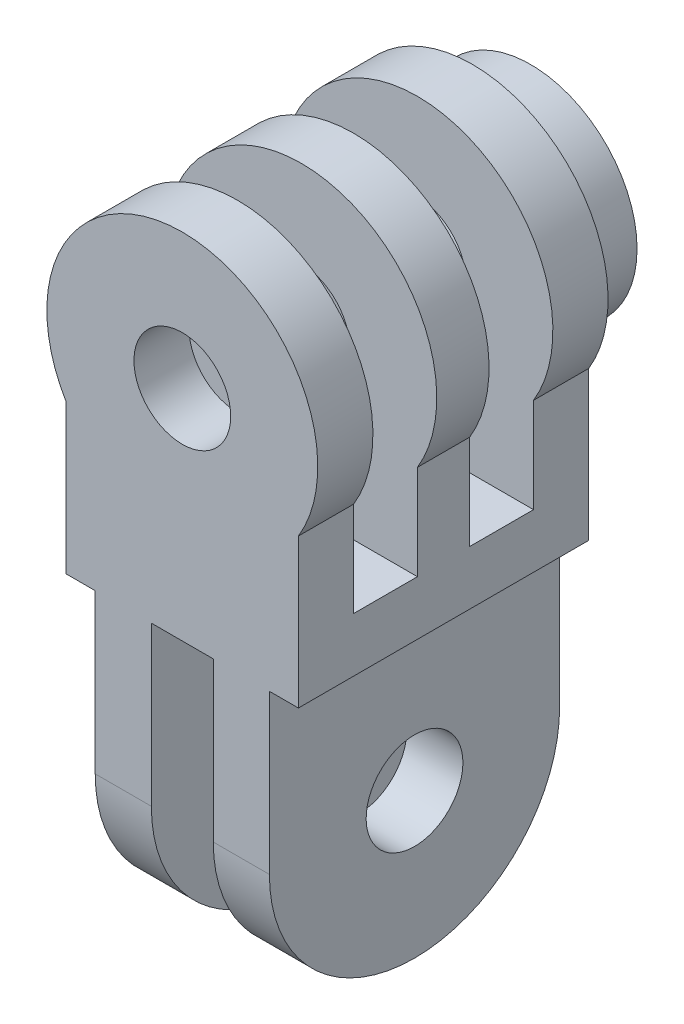
from build123d import *

# Parameters (mm, degrees)
ESQUISSE1_R                  = 2.5
BOSS_EXTRU_1_DEPTH           = 15
ESQUISSE2_W                  = 3.3
ESQUISSE2_H                  = 15.5
ENL_V_MAT_EXTRU_1_DEPTH      = 3.5
ENL_V_MAT_EXTRU_1_DEPTH_BACK = 12.5
ESQUISSE5_R                  = 2.5
ENL_V_MAT_EXTRU_4_DEPTH      = 10
ESQUISSE6_R                  = 5.5
ESQUISSE6_R_2                = 2.5
BOSS_EXTRU_2_DEPTH           = 3
ENL_V_MAT_EXTRU_5_DEPTH      = 3


with BuildPart() as part:
    # Esquisse1 → Boss.-Extru.1 (new body)
    with BuildSketch(Plane.XY):
        with BuildLine():
            Line((-4.5, -1.302598386), (-4.5, -17))
            Line((-4.5, -17), (-1.6, -17))
            Line((-1.6, -17), (-1.6, -1.302598386))
            Line((-1.6, -1.302598386), (1.6, -1.302598386))
            Line((1.6, -1.302598386), (1.6, -17))
            Line((1.6, -17), (4.5, -17))
            Line((4.5, -17), (4.5, -1.302598386))
            Line((4.5, -1.302598386), (6, -1.302598386))
            Line((6, -1.302598386), (6, 6.394448725))
            ThreePointArc((6, 6.394448725), (0, 3), (-6, 6.394448725))
            Line((-6, 6.394448725), (-6, -1.302598386))
            Line((-6, -1.302598386), (-4.5, -1.302598386))
        make_face()
        with BuildLine():
            Line((-6, 13.605551275), (-6, 6.394448725))
            ThreePointArc((-6, 6.394448725), (0, 3), (6, 6.394448725))
            Line((6, 6.394448725), (6, 13.605551275))
            ThreePointArc((6, 13.605551275), (3.446820352, 16.092571663), (0, 17))
            ThreePointArc((0, 17), (-3.446820352, 16.092571663), (-6, 13.605551275))
        make_face()
        with Locations((0, 10)):
            Circle(ESQUISSE1_R, mode=Mode.SUBTRACT)
        with BuildLine():
            Line((6, 13.605551275), (6, 6.394448725))
            ThreePointArc((6, 6.394448725), (6.745368782, 8.129171307), (7, 10))
            ThreePointArc((7, 10), (6.745368782, 11.870828693), (6, 13.605551275))
        make_face()
        with BuildLine():
            ThreePointArc((-6, 13.605551275), (-7, 10), (-6, 6.394448725))
            Line((-6, 6.394448725), (-6, 13.605551275))
        make_face()
    extrude(amount=BOSS_EXTRU_1_DEPTH)

    # Esquisse2 → Enlèv. mat.-Extru.1 (cut, two sides)
    with BuildSketch(Plane(origin=(4.5, 0, 0), x_dir=(0, 0, -1), z_dir=(1, 0, 0))) as enl_v_mat_extru_1_sk:
        with Locations((-10.5, 9.25)):
            Rectangle(ESQUISSE2_W, ESQUISSE2_H)
        with Locations((-4.5, 9.25)):
            Rectangle(ESQUISSE2_W, ESQUISSE2_H)
    extrude(amount=ENL_V_MAT_EXTRU_1_DEPTH, mode=Mode.SUBTRACT)
    extrude(enl_v_mat_extru_1_sk.sketch, amount=-ENL_V_MAT_EXTRU_1_DEPTH_BACK, mode=Mode.SUBTRACT)

    # Esquisse5 → Enlèv. mat.-Extru.4 (cut)
    with BuildSketch(Plane(origin=(4.5, 0, 0), x_dir=(0, 0, -1), z_dir=(1, 0, 0))):
        with BuildLine():
            ThreePointArc((-7.5, -17), (-12.803300859, -14.803300859), (-15, -9.5))
            Line((-15, -9.5), (-15, -17))
            Line((-15, -17), (-7.5, -17))
        make_face()
        with BuildLine():
            Line((0, -17), (0, -9.5))
            ThreePointArc((0, -9.5), (-2.196699141, -14.803300859), (-7.5, -17))
            Line((-7.5, -17), (0, -17))
        make_face()
        with Locations((-7.5, -9.5)):
            Circle(ESQUISSE5_R)
    extrude(amount=-ENL_V_MAT_EXTRU_4_DEPTH, mode=Mode.SUBTRACT)

    # Esquisse6 → Boss.-Extru.2 (add)
    with BuildSketch(Plane(origin=(0, 0, 0), x_dir=(-1, 0, 0), z_dir=(0, 0, -1))):
        with Locations((0, 10)):
            Circle(ESQUISSE6_R)
        with Locations((0, 10)):
            Circle(ESQUISSE6_R_2, mode=Mode.SUBTRACT)
    extrude(amount=BOSS_EXTRU_2_DEPTH)

    # Esquisse7 → Enlèv. mat.-Extru.5 (cut)
    with BuildSketch(Plane(origin=(0, 0, -3), x_dir=(-1, 0, 0), z_dir=(0, 0, -1))):
        Polygon((0, 14.70707265), (3.897114317, 12.45707265), (3.897114317, 7.95707265), (0, 5.70707265), (-3.897114317, 7.95707265), (-3.897114317, 12.45707265), align=None)
    extrude(amount=-ENL_V_MAT_EXTRU_5_DEPTH, mode=Mode.SUBTRACT)


solid = part.part
